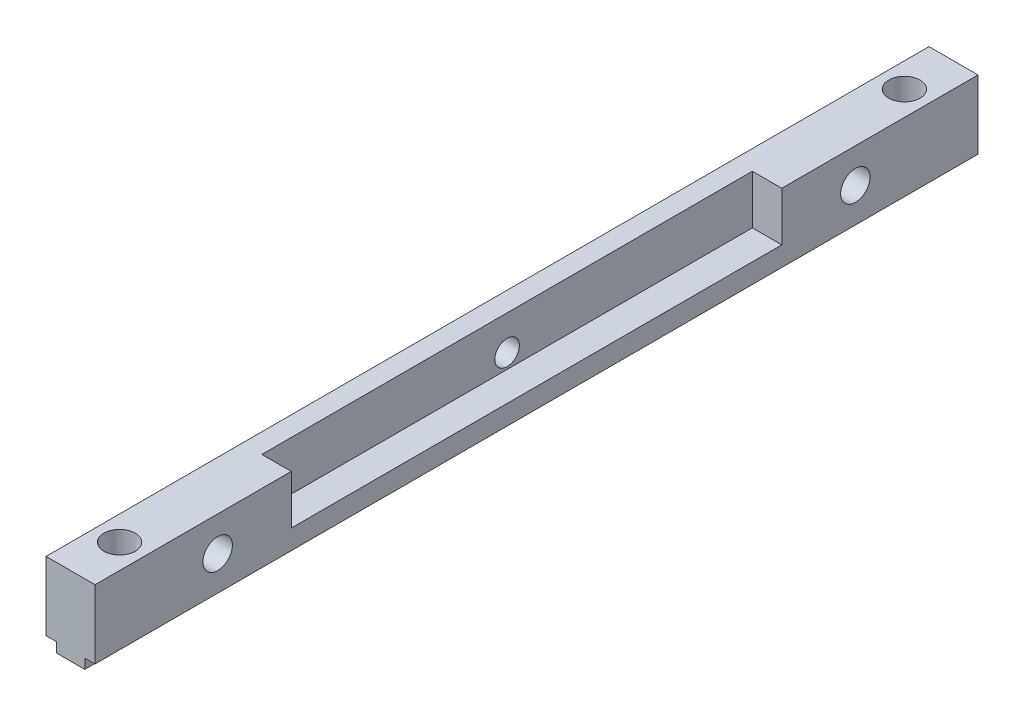
from build123d import *

# Parameters (mm, degrees)
MAIN_DEPTH               = 90
ESQUISSE2_R              = 1.5
HOLESFORPOWERBOARD_DEPTH = 6
ESQUISSE4_R              = 1.6
HOLESFORMAKERBEAM_DEPTH  = 9
SKETCH1_W                = 50
SKETCH1_H                = 5
POWERBOARDPINHOLES_DEPTH = 3
SKETCH2_R                = 1.25
WINDOWFIXHOLES_DEPTH     = 6


with BuildPart() as part:
    # Esquisse1 → Main (new body)
    with BuildSketch(Plane.XY):
        Polygon((0, 7), (5, 7), (5, 0), (3.95, 0), (3.95, -1), (1.05, -1), (1.05, 0), (0, 0), align=None)
    extrude(amount=MAIN_DEPTH)

    # Esquisse2 → HolesForPowerBoard (cut, through all)
    with BuildSketch(Plane(origin=(5, 0, 0), x_dir=(0, 0, -1), z_dir=(1, 0, 0))):
        with Locations((-12.5, 3.5)):
            Circle(ESQUISSE2_R)
        with Locations((-77.5, 3.5)):
            Circle(ESQUISSE2_R)
    extrude(amount=-HOLESFORPOWERBOARD_DEPTH, mode=Mode.SUBTRACT)

    # Esquisse4 → HolesForMakerBeam (cut, through all)
    with BuildSketch(Plane(origin=(0, -1, 0), x_dir=(-1, 0, 0), z_dir=(0, -1, 0))):
        with Locations((-2.5, -85)):
            Circle(ESQUISSE4_R)
        with Locations((-2.5, -5)):
            Circle(ESQUISSE4_R)
    extrude(amount=-HOLESFORMAKERBEAM_DEPTH, mode=Mode.SUBTRACT)

    # Sketch1 → PowerBoardPinHoles (cut)
    with BuildSketch(Plane(origin=(5, 0, 0), x_dir=(0, 0, -1), z_dir=(1, 0, 0))):
        with Locations((-45, 4.5)):
            Rectangle(SKETCH1_W, SKETCH1_H)
    extrude(amount=-POWERBOARDPINHOLES_DEPTH, mode=Mode.SUBTRACT)

    # Sketch2 → WindowFixHoles (cut, through all)
    with BuildSketch(Plane.ZY):
        with Locations((45, 3.5)):
            Circle(SKETCH2_R)
    extrude(amount=-WINDOWFIXHOLES_DEPTH, mode=Mode.SUBTRACT)


solid = part.part
